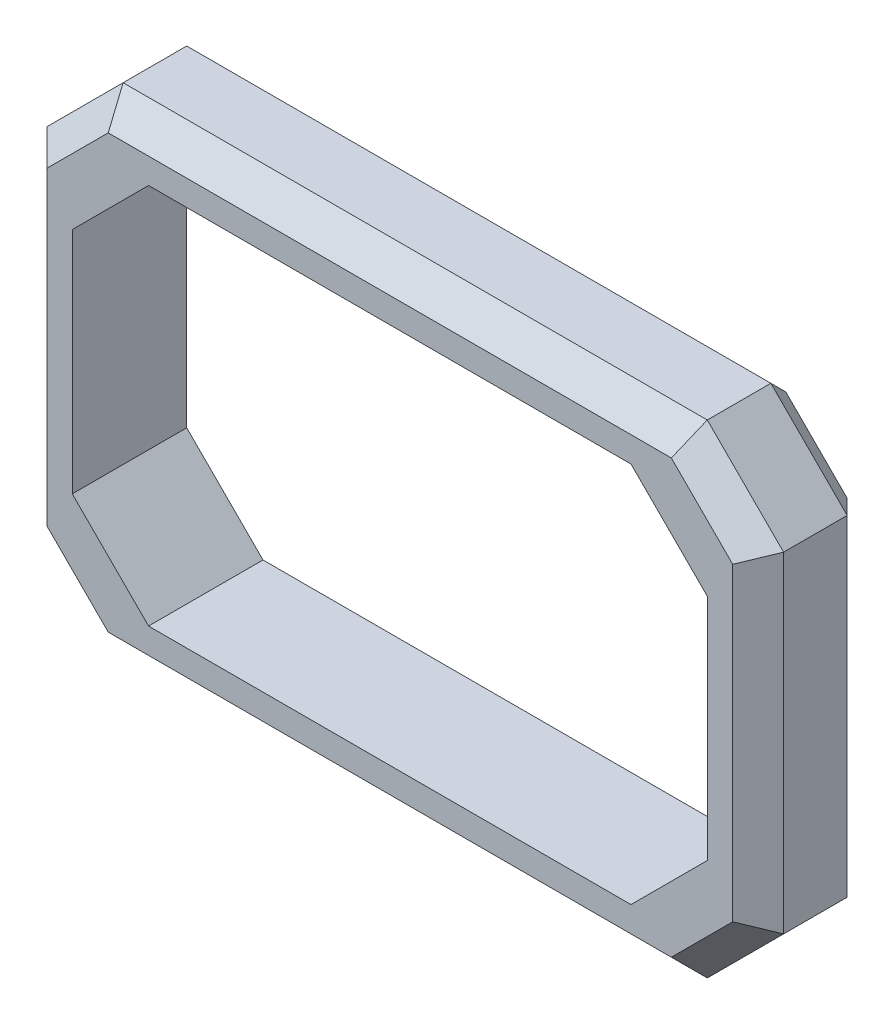
from build123d import *

# Parameters (mm, degrees)
ESBO_O1_W                = 289.676219128
ESBO_O1_H                = 190
ESBO_O1_W_2              = 249.676219128
ESBO_O1_H_2              = 150
RESSALTO_EXTRUS_O1_DEPTH = 45
CHANFRO1_SIZE            = 30
CHANFRO2_SIZE            = 10


with BuildPart() as part:
    # Esboço1 → Ressalto-extrusão1 (new body)
    with BuildSketch(Plane.XY):
        Rectangle(ESBO_O1_W, ESBO_O1_H)
        Rectangle(ESBO_O1_W_2, ESBO_O1_H_2, mode=Mode.SUBTRACT)
    extrude(amount=RESSALTO_EXTRUS_O1_DEPTH)

    # Chanfro1
    chanfro1_edges = [part.edges().sort_by_distance(p)[0] for p in [
        (124.838109564, -75, 22.5),
        (124.838109564, 75, 22.5),
        (-124.838109564, 75, 22.5),
        (-124.838109564, -75, 22.5),
        (-144.838109564, 95, 22.5),
        (144.838109564, 95, 22.5),
        (144.838109564, -95, 22.5),
        (-144.838109564, -95, 22.5),
    ]]
    chamfer(chanfro1_edges, length=CHANFRO1_SIZE)

    # Chanfro2
    chanfro2_edges = [part.edges().sort_by_distance(p)[0] for p in [
        (144.838109564, 0, 0),
        (144.838109564, 0, 45),
        (-144.838109564, 0, 0),
        (0, 95, 0),
        (0, -95, 0),
        (-129.838109564, 80, 0),
        (-129.838109564, -80, 0),
        (129.838109564, 80, 0),
        (129.838109564, -80, 0),
        (0, -95, 45),
        (-144.838109564, 0, 45),
        (0, 95, 45),
        (-129.838109564, 80, 45),
        (-129.838109564, -80, 45),
        (129.838109564, 80, 45),
        (129.838109564, -80, 45),
    ]]
    chamfer(chanfro2_edges, length=CHANFRO2_SIZE)


solid = part.part
